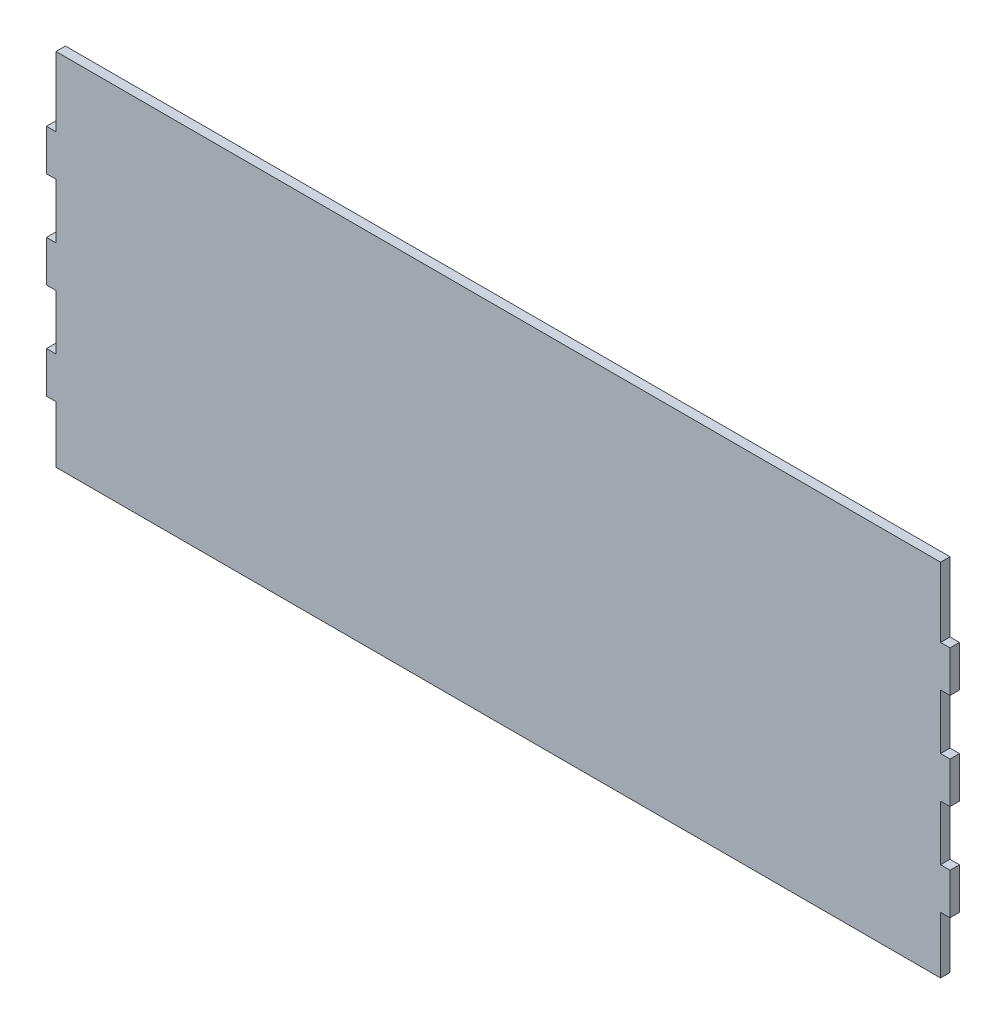
from build123d import *

# Parameters (mm, degrees)
CROQUIS1_W              = 286.03
CROQUIS1_H              = 110
SALIENTE_EXTRUIR1_DEPTH = 3
CROQUIS2_W              = 3
CROQUIS2_H              = 17.427708433
CORTAR_EXTRUIR1_DEPTH   = 3
CROQUIS4_W              = 280.03
CROQUIS4_H              = 4
SALIENTE_EXTRUIR3_DEPTH = 3
CROQUIS6_W              = 2.243589743
CROQUIS6_H              = 25
CORTAR_EXTRUIR4_DEPTH   = 1.5


with BuildPart() as part:
    # Croquis1 → Saliente-Extruir1 (new body)
    with BuildSketch(Plane.XY):
        Rectangle(CROQUIS1_W, CROQUIS1_H)
    extrude(amount=SALIENTE_EXTRUIR1_DEPTH)

    # Croquis2 → Cortar-Extruir1 (cut)
    with BuildSketch(Plane.XY.offset(3)):
        Polygon((-143.015, 55), (-143.015, 37), (-140.015, 37), (-140.015, 52), (-140.015, 55), align=None)
        with Locations((-141.515, 15.237951406)):
            Rectangle(CROQUIS2_W, CROQUIS2_H)
        Polygon((140.015, 55), (140.015, 52), (140.015, 37), (143.015, 37), (143.015, 55), align=None)
        with Locations((141.515, 15.237951406)):
            Rectangle(CROQUIS2_W, CROQUIS2_H)
        with Locations((141.515, -15.237951406)):
            Rectangle(CROQUIS2_W, CROQUIS2_H)
        Polygon((140.015, -37), (140.015, -52), (140.015, -55), (143.015, -55), (143.015, -37), align=None)
        with Locations((-141.515, -15.237951406)):
            Rectangle(CROQUIS2_W, CROQUIS2_H)
        Polygon((-140.015, -37), (-143.015, -37), (-143.015, -55), (-140.015, -55), (-140.015, -52), align=None)
    extrude(amount=-CORTAR_EXTRUIR1_DEPTH, mode=Mode.SUBTRACT)

    # Croquis4 → Saliente-Extruir3 (add)
    with BuildSketch(Plane(origin=(0, 0, 0), x_dir=(-1, 0, 0), z_dir=(0, 0, -1))):
        with Locations((0, 57)):
            Rectangle(CROQUIS4_W, CROQUIS4_H)
    extrude(amount=-SALIENTE_EXTRUIR3_DEPTH)

    # Croquis6 → Cortar-Extruir4 (cut)
    with BuildSketch(Plane(origin=(0, 0, 0), x_dir=(-1, 0, 0), z_dir=(0, 0, -1))):
        with Locations((-95.765179816, 1.792158121)):
            Rectangle(CROQUIS6_W, CROQUIS6_H)
        Polygon((-91.117743918, 11.728055557), (-91.117743918, 14.292158121), (-77.976718277, 14.292158121), (-77.976718277, 11.728055557), (-83.425436226, 11.728055557), (-83.425436226, -10.707841879), (-85.669025969, -10.707841879), (-85.669025969, 11.728055557), align=None)
        Polygon((-63.874154175, 14.292158121), (-52.335692636, -10.707841879), (-54.77459488, -10.707841879), (-58.470508341, -2.695021367), (-69.803641354, -2.695021367), (-73.599715072, -10.707841879), (-76.053641354, -10.707841879), (-64.194666995, 14.292158121), align=None)
        Polygon((-64.059450649, 9.414353633), (-68.581686226, -0.130918802), (-59.652399367, -0.130918802), align=None, mode=Mode.SUBTRACT)
        Polygon((-49.130564431, -10.707841879), (-45.830283982, 14.292158121), (-45.509771162, 14.292158121), (-35.188256739, -6.220662392), (-24.896790393, 14.292158121), (-24.576277572, 14.292158121), (-21.245949046, -10.707841879), (-23.48953879, -10.707841879), (-25.893384944, 7.265916133), (-34.912816034, -10.707841879), (-35.423633341, -10.707841879), (-44.483128534, 7.321004274), (-46.871950649, -10.707841879), align=None)
        Polygon((-7.784410585, -10.707841879), (-4.484130136, 14.292158121), (-4.163617316, 14.292158121), (6.157897107, -6.220662392), (16.449363454, 14.292158121), (16.769876274, 14.292158121), (20.1002048, -10.707841879), (17.856615056, -10.707841879), (15.452768902, 7.265916133), (6.433337813, -10.707841879), (5.922520505, -10.707841879), (-3.136974687, 7.321004274), (-5.525796803, -10.707841879), align=None)
        Polygon((35.484820184, 14.292158121), (47.023281723, -10.707841879), (44.584379479, -10.707841879), (40.888466018, -2.695021367), (29.555333005, -2.695021367), (25.759259287, -10.707841879), (23.305333005, -10.707841879), (35.164307364, 14.292158121), align=None)
        Polygon((35.29952371, 9.414353633), (30.777288133, -0.130918802), (39.706574992, -0.130918802), align=None, mode=Mode.SUBTRACT)
        Polygon((51.51046121, -10.707841879), (51.51046121, 14.292158121), (51.981214415, 14.292158121), (68.497640697, -5.384324251), (68.497640697, 14.292158121), (70.741230441, 14.292158121), (70.741230441, -10.707841879), (70.230413133, -10.707841879), (53.754050954, 8.923568377), (53.754050954, -10.707841879), align=None)
        Polygon((74.266871466, 11.728055557), (74.266871466, 14.292158121), (87.407897107, 14.292158121), (87.407897107, 11.728055557), (81.959179159, 11.728055557), (81.959179159, -10.707841879), (79.715589415, -10.707841879), (79.715589415, 11.728055557), align=None)
        with Locations((92.375845826, 1.792158121)):
            Rectangle(CROQUIS6_W, CROQUIS6_H)
        with BuildLine():
            Line((97.343794543, -5.885125533), (99.457175954, -4.61809829))
            add(Edge.make_bspline(
                [(99.457175954, -4.61809829), (99.653734791, -4.947129611), (100.030333938, -5.577540924), (100.658557932, -6.42938407), (101.309507298, -7.153399476), (101.988002537, -7.745375244), (102.689902167, -8.211438721), (103.419788265, -8.541454661), (104.175201199, -8.747283057), (104.689299924, -8.772283675), (104.945958005, -8.784764956)],
                knots=[0, 0, 0, 0, 1.272034388, 2.437168799, 3.508375237, 4.49857839, 5.41946034, 6.295179144, 7.148887113, 8, 8, 8, 8], degree=3))
            add(Edge.make_bspline(
                [(104.945958005, -8.784764956), (105.165149866, -8.778660153), (105.599698245, -8.766557365), (106.239428551, -8.650265922), (106.860727139, -8.471607858), (107.450788837, -8.215744062), (108.001471798, -7.906183449), (108.484376765, -7.532282181), (108.901849002, -7.113666426), (109.243342677, -6.646647465), (109.505342929, -6.144382117), (109.706714847, -5.628839608), (109.818465373, -5.091921263), (109.835299326, -4.730417957), (109.843794543, -4.54798611)],
                knots=[0, 0, 0, 0, 1.095163259, 2.171163733, 3.241058638, 4.321873601, 5.38011039, 6.391990106, 7.366004449, 8.327778327, 9.272591725, 10.192022065, 11.087607919, 12, 12, 12, 12], degree=3))
            add(Edge.make_bspline(
                [(109.843794543, -4.54798611), (109.833263753, -4.339837184), (109.811856194, -3.916700833), (109.630917051, -3.292417597), (109.346279573, -2.674613526), (109.083689261, -2.292461629), (108.947360248, -2.094059828)],
                knots=[0, 0, 0, 0, 0.938893495, 1.908633276, 2.914225137, 4, 4, 4, 4], degree=3))
            add(Edge.make_bspline(
                [(108.947360248, -2.094059828), (108.83542729, -1.950868231), (108.600438045, -1.650255384), (108.196455812, -1.202789416), (107.722412139, -0.741229281), (107.194529604, -0.247950303), (106.593578969, 0.254105388), (105.938382438, 0.788878802), (105.212212016, 1.336032923), (104.702929898, 1.70297982), (104.44014871, 1.892318377)],
                knots=[0, 0, 0, 0, 0.722233717, 1.516239348, 2.393582979, 3.351407094, 4.387010283, 5.505090956, 6.712668013, 8, 8, 8, 8], degree=3))
            add(Edge.make_bspline(
                [(104.44014871, 1.892318377), (104.177120166, 2.079665431), (103.674229619, 2.437858733), (102.970954031, 2.969460762), (102.342065009, 3.455488401), (101.790357748, 3.900517059), (101.316074914, 4.304607093), (100.915479121, 4.663878087), (100.598775141, 4.988046379), (100.422663851, 5.198341677), (100.343594223, 5.292759082)],
                knots=[0, 0, 0, 0, 1.452282411, 2.77665338, 3.964542531, 5.026858415, 5.96415736, 6.766646006, 7.446254459, 8, 8, 8, 8], degree=3))
            add(Edge.make_bspline(
                [(100.343594223, 5.292759082), (100.233076043, 5.439909345), (100.015727209, 5.729300087), (99.72882717, 6.181620499), (99.484976007, 6.644643824), (99.293816492, 7.119614285), (99.1328435, 7.599863777), (99.024572566, 8.091658389), (98.956776874, 8.592791378), (98.949834113, 8.930030668), (98.946358646, 9.098848826)],
                knots=[0, 0, 0, 0, 1.068054152, 2.10047183, 3.106115577, 4.101338837, 5.06977816, 6.043150881, 7.020423561, 8, 8, 8, 8], degree=3))
            add(Edge.make_bspline(
                [(98.946358646, 9.098848826), (98.955681567, 9.363347216), (98.974128139, 9.886690528), (99.130131834, 10.65119646), (99.376366789, 11.38109944), (99.721330273, 12.069173252), (100.166025651, 12.697501687), (100.680639754, 13.273312308), (101.293578941, 13.75737361), (101.966097679, 14.180316884), (102.702214622, 14.511359207), (103.473578218, 14.761080494), (104.281414447, 14.902575192), (104.828579694, 14.922880655), (105.106214415, 14.933183762)],
                knots=[0, 0, 0, 0, 1.005424448, 1.989358655, 2.955360095, 3.929531133, 4.905563448, 5.876582895, 6.856512386, 7.866279853, 8.892233794, 9.918561126, 10.94386622, 12, 12, 12, 12], degree=3))
            add(Edge.make_bspline(
                [(105.106214415, 14.933183762), (105.400815132, 14.923022679), (105.98668193, 14.902815528), (106.848462041, 14.727118876), (107.678181444, 14.436399792), (108.345633335, 14.106480806), (108.868010203, 13.776970694), (109.266386865, 13.476829092), (109.670082942, 13.131292602), (110.082354762, 12.739440844), (110.496216615, 12.297678336), (110.917812703, 11.809030558), (111.348128909, 11.276483731), (111.624956481, 10.896308725), (111.766871466, 10.701412928)],
                knots=[0, 0, 0, 0, 1.286793592, 2.559021753, 3.825965368, 5.121522368, 5.803751409, 6.523245864, 7.299691795, 8.125521123, 9.008227632, 9.944561021, 10.946284179, 12, 12, 12, 12], degree=3))
            Line((111.766871466, 10.701412928), (109.738626274, 9.163952992))
            add(Edge.make_bspline(
                [(109.738626274, 9.163952992), (109.616155328, 9.321729353), (109.38030492, 9.625569733), (109.022237157, 10.05107913), (108.684746815, 10.439768269), (108.352243959, 10.777376327), (108.042289449, 11.082391565), (107.741453433, 11.343532685), (107.454065209, 11.563358367), (107.091801562, 11.797955224), (106.636675002, 12.030501678), (106.065356886, 12.227280807), (105.468312065, 12.345531249), (105.06167184, 12.36116616), (104.855813774, 12.369081198)],
                knots=[0, 0, 0, 0, 1.181633172, 2.275549214, 3.290209073, 4.226197932, 5.078386478, 5.862611352, 6.581680152, 7.217281963, 8.414376989, 9.595101626, 10.782541182, 12, 12, 12, 12], degree=3))
            add(Edge.make_bspline(
                [(104.855813774, 12.369081198), (104.5975529, 12.360426198), (104.099521133, 12.343735846), (103.392448017, 12.161450237), (102.756062838, 11.874436949), (102.209258802, 11.472187106), (101.753994681, 10.995608587), (101.424669975, 10.447188193), (101.226454514, 9.841599603), (101.202266802, 9.419159201), (101.189948389, 9.204017095)],
                knots=[0, 0, 0, 0, 1.14458467, 2.207223713, 3.21896685, 4.227309161, 5.202851033, 6.127160689, 7.046193047, 8, 8, 8, 8], degree=3))
            add(Edge.make_bspline(
                [(101.189948389, 9.204017095), (101.192756437, 9.070077963), (101.198377123, 8.801980681), (101.276768535, 8.405899095), (101.377478028, 8.0108181), (101.537068255, 7.618513937), (101.757391852, 7.222125658), (102.046714537, 6.814827532), (102.411095337, 6.393029613), (102.690216854, 6.118691229), (102.837584607, 5.973848826)],
                knots=[0, 0, 0, 0, 0.858281714, 1.717966888, 2.583508476, 3.4729293, 4.427298488, 5.488583878, 6.674047936, 8, 8, 8, 8], degree=3))
            add(Edge.make_bspline(
                [(102.837584607, 5.973848826), (102.892308696, 5.925012927), (103.022320604, 5.80899001), (103.260005788, 5.619045149), (103.573882918, 5.384739632), (103.955755784, 5.094830229), (104.41266551, 4.758534071), (104.94466234, 4.380151127), (105.545816146, 3.947397848), (105.97240126, 3.644843987), (106.19796121, 3.484866454)],
                knots=[0, 0, 0, 0, 0.420754252, 0.999615792, 1.744751191, 2.668019286, 3.750313428, 4.999500688, 6.413464383, 8, 8, 8, 8], degree=3))
            add(Edge.make_bspline(
                [(106.19796121, 3.484866454), (106.469289162, 3.287428171), (106.994678136, 2.905116302), (107.742232279, 2.330718587), (108.420045194, 1.768948812), (109.030496648, 1.223394475), (109.579617422, 0.698193811), (110.061315427, 0.187028237), (110.480498858, -0.306440139), (110.93177899, -0.939101394), (111.392906272, -1.716109139), (111.78891704, -2.668096557), (112.038619521, -3.62378456), (112.071273203, -4.266119107), (112.087384287, -4.5830422)],
                knots=[0, 0, 0, 0, 1.163667725, 2.253281268, 3.268753668, 4.215851969, 5.092017293, 5.902905408, 6.650798638, 7.335211899, 8.59617414, 9.77448103, 10.901945474, 12, 12, 12, 12], degree=3))
            add(Edge.make_bspline(
                [(112.087384287, -4.5830422), (112.082690443, -4.807173379), (112.073393907, -5.251083262), (111.966530237, -5.902905239), (111.8099612, -6.53598288), (111.573980958, -7.142490826), (111.285958399, -7.733524845), (110.9204852, -8.293581277), (110.49685888, -8.835055552), (110.010903417, -9.343509062), (109.479146971, -9.810267605), (108.917120581, -10.225475187), (108.323904346, -10.571677497), (107.702716369, -10.854183511), (107.053413964, -11.075137208), (106.376215508, -11.23522913), (105.670004714, -11.333484208), (105.190001274, -11.343682504), (104.945958005, -11.34886752)],
                knots=[0, 0, 0, 0, 0.983748083, 1.948392443, 2.894712957, 3.844097841, 4.80183111, 5.778335162, 6.776009319, 7.81870978, 8.863265674, 9.881300176, 10.883814829, 11.87499822, 12.874611388, 13.892143829, 14.928324115, 16, 16, 16, 16], degree=3))
            add(Edge.make_bspline(
                [(104.945958005, -11.34886752), (104.757134126, -11.345216223), (104.381864412, -11.337959613), (103.826796684, -11.27380761), (103.282942476, -11.183042585), (102.757126175, -11.038942085), (102.242573235, -10.864106535), (101.74152156, -10.64883273), (101.253728318, -10.39085272), (100.776459869, -10.095888258), (100.31093005, -9.752618654), (99.86150528, -9.352807965), (99.413439669, -8.90748293), (98.979958266, -8.404550334), (98.55229295, -7.852135457), (98.138875739, -7.245069861), (97.731149184, -6.586660191), (97.475324414, -6.123338151), (97.343794543, -5.885125533)],
                knots=[0, 0, 0, 0, 0.915332311, 1.819136955, 2.706846663, 3.586547465, 4.459518054, 5.340707479, 6.227863349, 7.133153174, 8.059268498, 9.028702269, 10.047606654, 11.120612155, 12.245963614, 13.433783089, 14.680604001, 16, 16, 16, 16], degree=3))
        make_face()
    extrude(amount=-CORTAR_EXTRUIR4_DEPTH, mode=Mode.SUBTRACT)


solid = part.part
